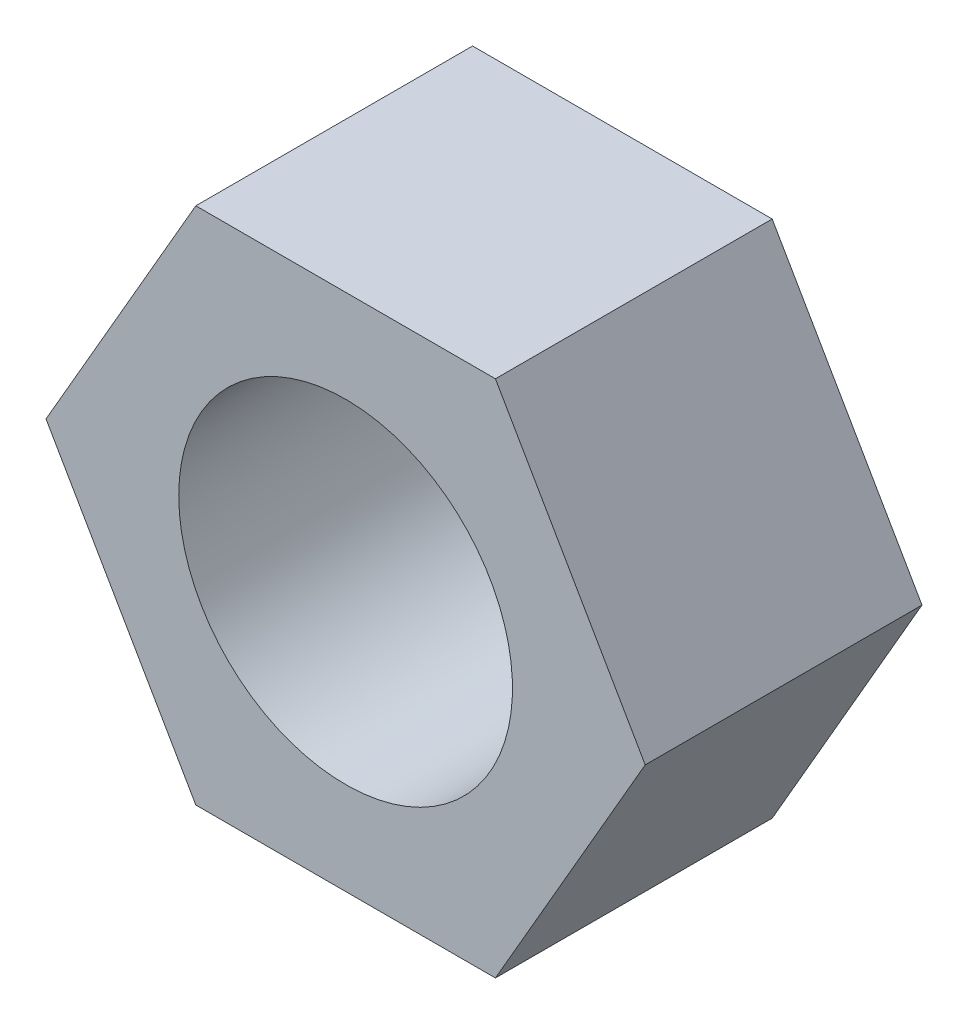
from build123d import *

# Parameters (mm, degrees)
BOSS_EXTRUDE1_DEPTH = 16
SKETCH2_R           = 9.647
CUT_EXTRUDE1_DEPTH  = 16


with BuildPart() as part:
    # Sketch1 → Boss-Extrude1 (new body)
    with BuildSketch(Plane.XY):
        Polygon((8.660254038, -15), (17.320508076, 0), (8.660254038, 15), (-8.660254038, 15), (-17.320508076, 0), (-8.660254038, -15), align=None)
    extrude(amount=BOSS_EXTRUDE1_DEPTH)

    # Sketch2 → Cut-Extrude1 (cut)
    with BuildSketch(Plane(origin=(0, 0, 0), x_dir=(-1, 0, 0), z_dir=(0, 0, -1))):
        Circle(SKETCH2_R)
    extrude(amount=-CUT_EXTRUDE1_DEPTH, mode=Mode.SUBTRACT)


solid = part.part
